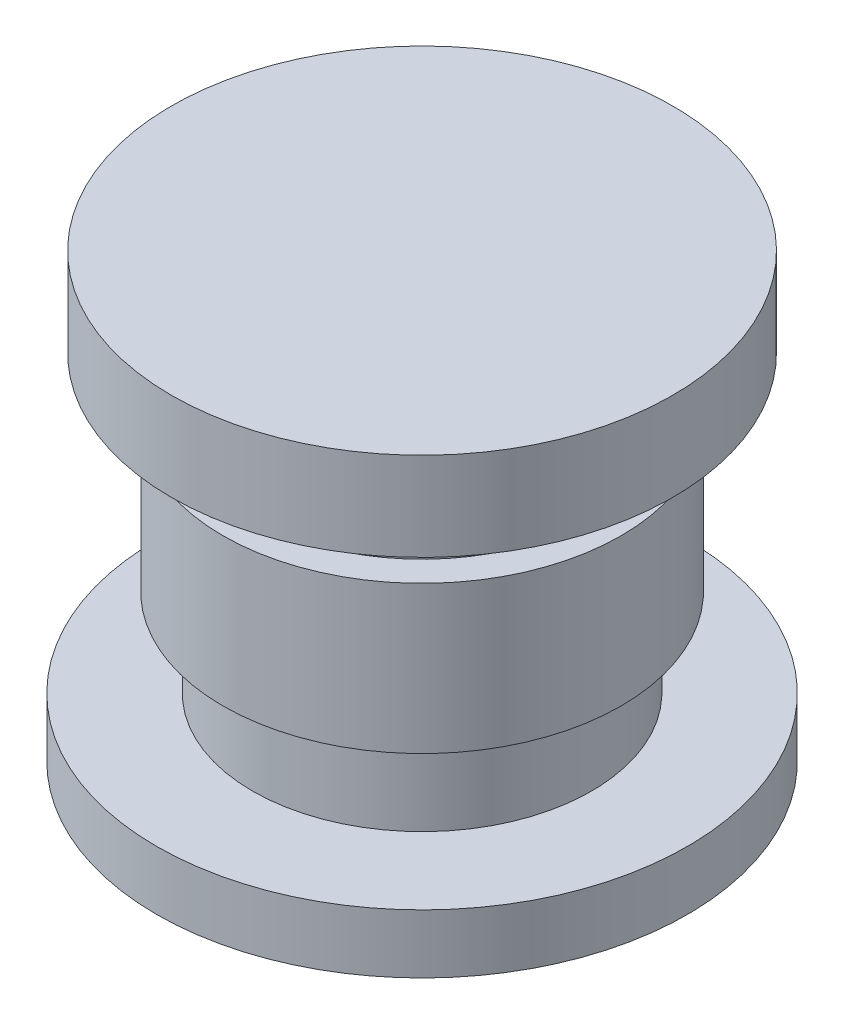
from build123d import *

# Parameters (mm, degrees)
SKETCH1_R           = 9
BOSS_EXTRUDE1_DEPTH = 2
SKETCH2_R           = 5.75
BOSS_EXTRUDE2_DEPTH = 3
SKETCH3_R           = 6.75
BOSS_EXTRUDE3_DEPTH = 5
SKETCH4_R           = 5.75
BOSS_EXTRUDE4_DEPTH = 2
SKETCH5_R           = 8.5
BOSS_EXTRUDE5_DEPTH = 3


with BuildPart() as part:
    # Sketch1 → Boss-Extrude1 (new body)
    with BuildSketch(Plane(origin=(0, 0, 0), x_dir=(1, 0, 0), z_dir=(0, 1, 0))):
        Circle(SKETCH1_R)
    extrude(amount=BOSS_EXTRUDE1_DEPTH)

    # Sketch2 → Boss-Extrude2 (add)
    with BuildSketch(Plane(origin=(0, 2, 0), x_dir=(1, 0, 0), z_dir=(0, 1, 0))):
        Circle(SKETCH2_R)
    extrude(amount=BOSS_EXTRUDE2_DEPTH)

    # Sketch3 → Boss-Extrude3 (add)
    with BuildSketch(Plane(origin=(0, 5, 0), x_dir=(1, 0, 0), z_dir=(0, 1, 0))):
        Circle(SKETCH3_R)
    extrude(amount=BOSS_EXTRUDE3_DEPTH)

    # Sketch4 → Boss-Extrude4 (add)
    with BuildSketch(Plane(origin=(0, 10, 0), x_dir=(1, 0, 0), z_dir=(0, 1, 0))):
        Circle(SKETCH4_R)
    extrude(amount=BOSS_EXTRUDE4_DEPTH)

    # Sketch5 → Boss-Extrude5 (add)
    with BuildSketch(Plane(origin=(0, 12, 0), x_dir=(1, 0, 0), z_dir=(0, 1, 0))):
        Circle(SKETCH5_R)
    extrude(amount=BOSS_EXTRUDE5_DEPTH)


solid = part.part
